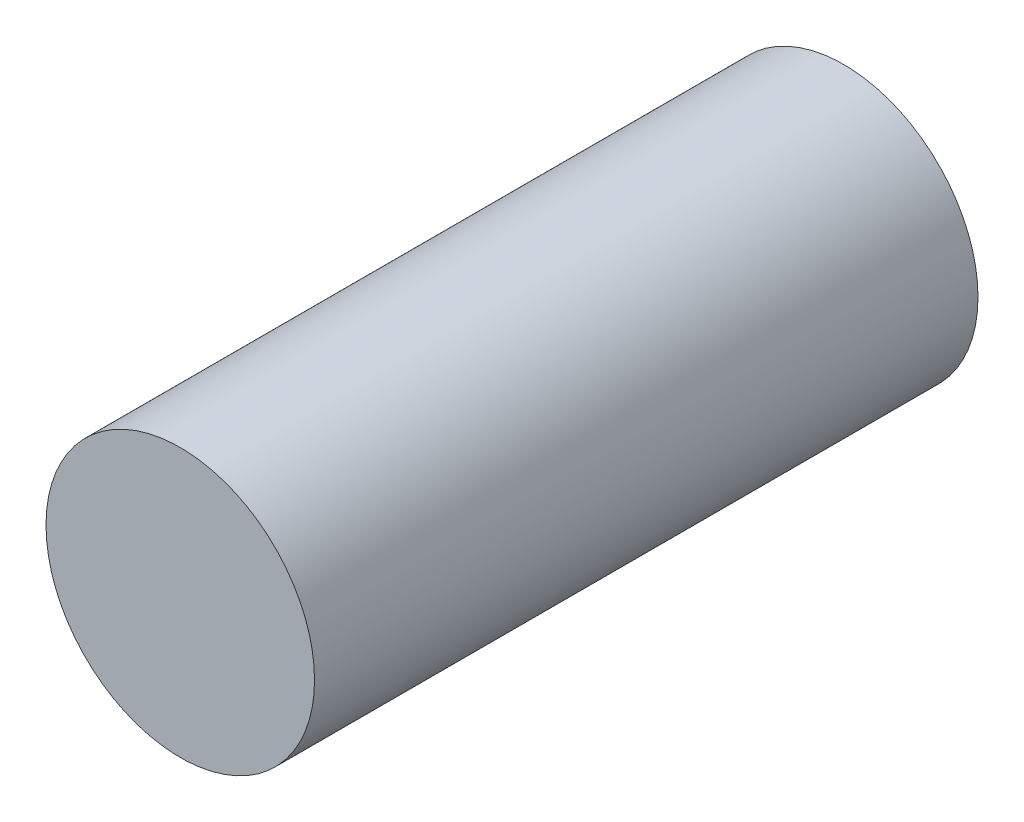
from build123d import *

# Parameters (mm, degrees)
SKETCH1_R           = 8.5
BOSS_EXTRUDE1_DEPTH = 42


with BuildPart() as part:
    # Sketch1 → Boss-Extrude1 (new body)
    with BuildSketch(Plane.XY):
        Circle(SKETCH1_R)
    extrude(amount=BOSS_EXTRUDE1_DEPTH)


solid = part.part
